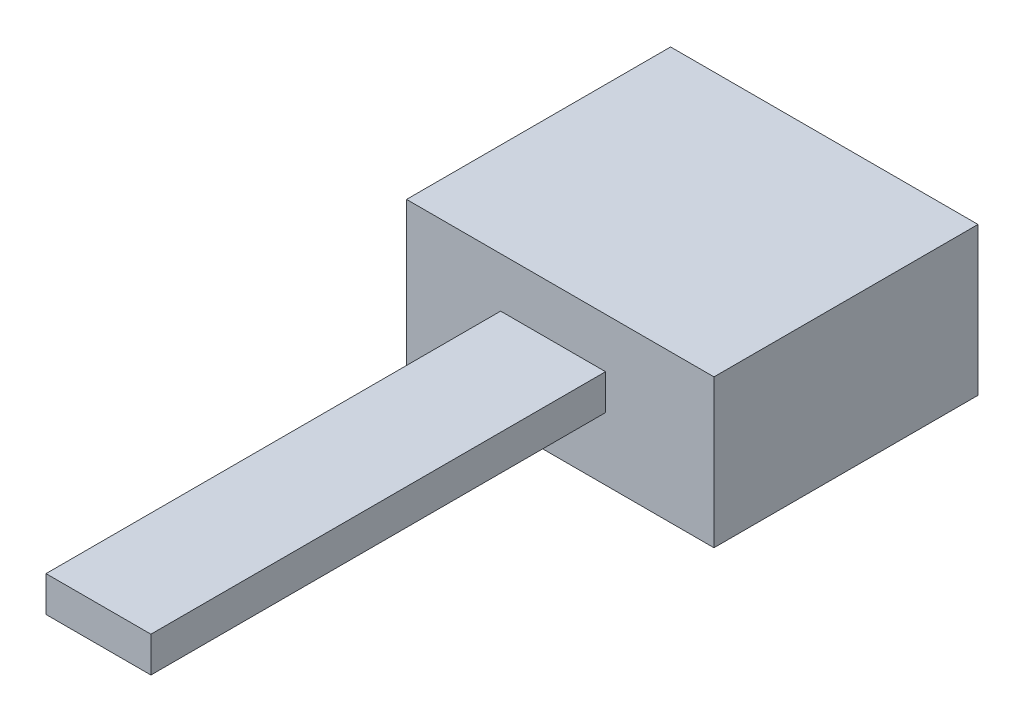
from build123d import *

# Parameters (mm, degrees)
SKETCH1_W           = 44.6532
SKETCH1_H           = 38.354
BOSS_EXTRUDE1_DEPTH = 21.5
SKETCH2_W           = 15.24
SKETCH2_H           = 5.142082165
BOSS_EXTRUDE2_DEPTH = 66.04


with BuildPart() as part:
    # Sketch1 → Boss-Extrude1 (new body)
    with BuildSketch(Plane(origin=(0, 0, 0), x_dir=(1, 0, 0), z_dir=(0, 1, 0))):
        with Locations((22.3266, 19.177)):
            Rectangle(SKETCH1_W, SKETCH1_H)
    extrude(amount=BOSS_EXTRUDE1_DEPTH)

    # Sketch2 → Boss-Extrude2 (add)
    with BuildSketch(Plane.XY):
        with Locations((21.287326566, 11.707107753)):
            Rectangle(SKETCH2_W, SKETCH2_H)
    extrude(amount=BOSS_EXTRUDE2_DEPTH)


solid = part.part
